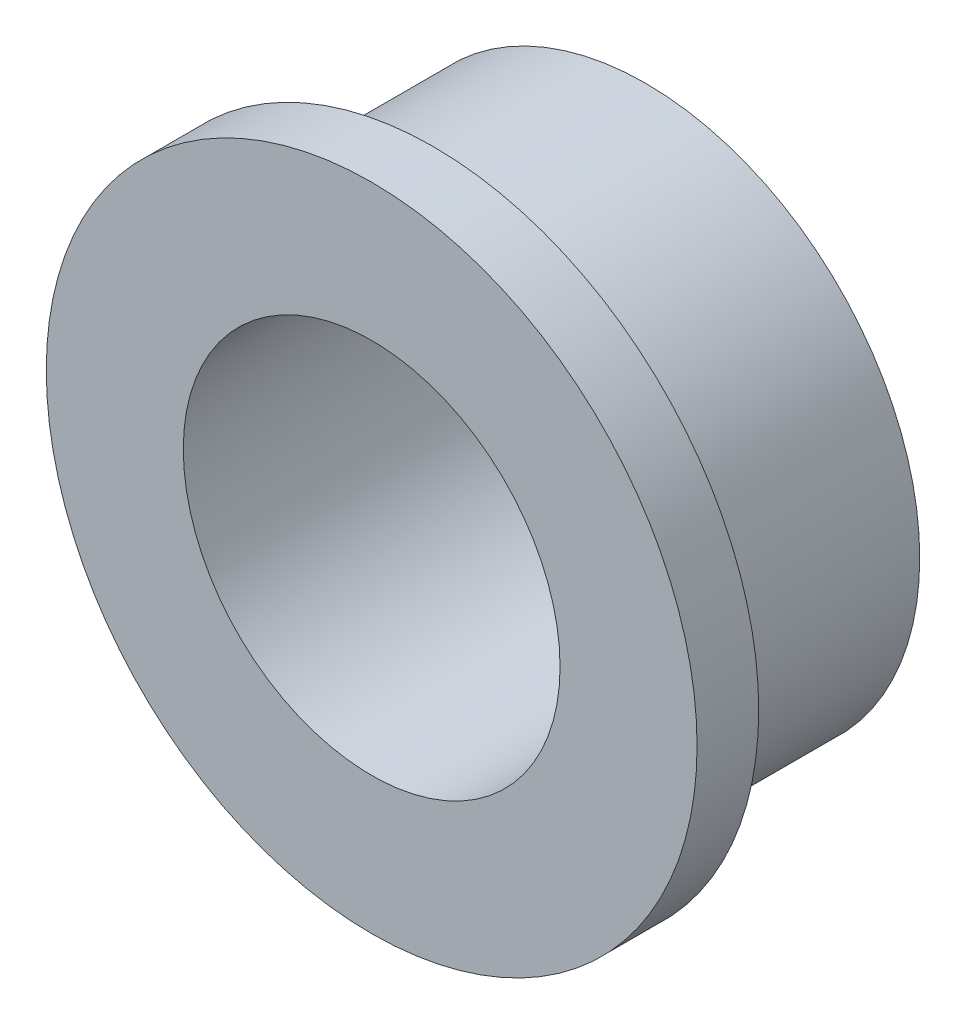
from build123d import *

# Parameters (mm, degrees)
SKETCH_1_R          = 4
EXTRUDE_1_DEPTH     = 3.1
SKETCH_2_R          = 4.75
EXTRUDE_2_DEPTH     = 0.9
SKETCH_3_R          = 2.75
CUT_EXTRUDE_1_DEPTH = 5


with BuildPart() as part:
    # 草图1 → 凸台-拉伸1 (new body)
    with BuildSketch(Plane.XY):
        Circle(SKETCH_1_R)
    extrude(amount=EXTRUDE_1_DEPTH)

    # 草图2 → 凸台-拉伸2 (add)
    with BuildSketch(Plane.XY.offset(3.1)):
        Circle(SKETCH_2_R)
    extrude(amount=EXTRUDE_2_DEPTH)

    # 草图3 → 切除-拉伸1 (cut, through all)
    with BuildSketch(Plane(origin=(0, 0, 0), x_dir=(-1, 0, 0), z_dir=(0, 0, -1))):
        Circle(SKETCH_3_R)
    extrude(amount=-CUT_EXTRUDE_1_DEPTH, mode=Mode.SUBTRACT)


solid = part.part
